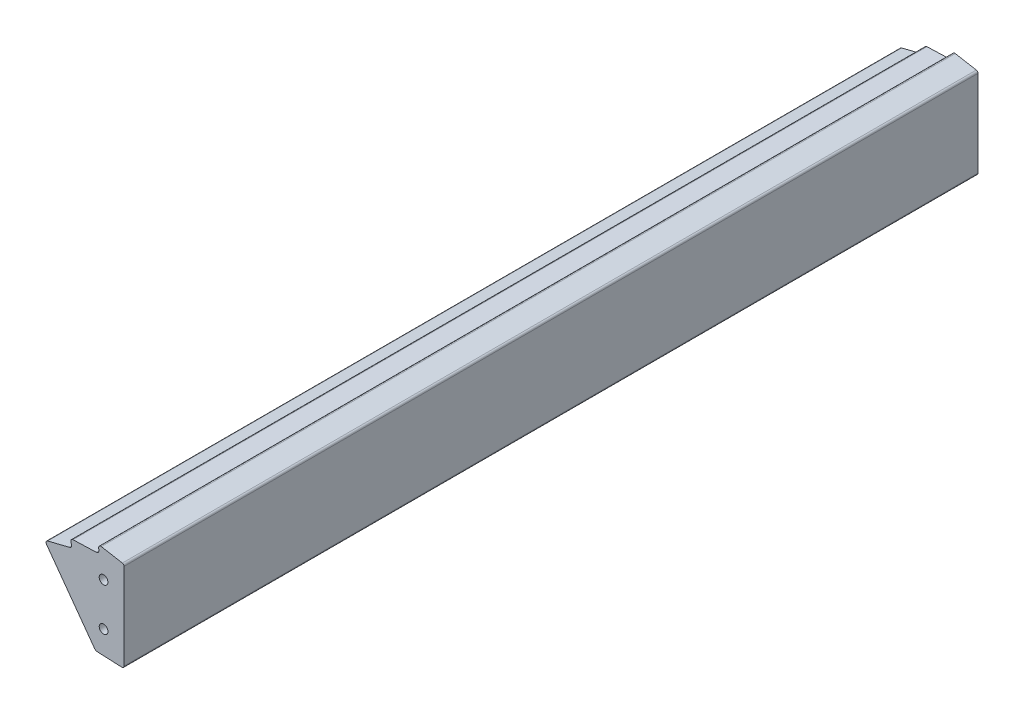
from build123d import *

# Parameters (mm, degrees)
EXTRUDE_THIN1_DEPTH                   = 137.50025
EXTRUDE_THIN1_DEPTH_BACK              = 213.5
BOSS_EXTRUDE1_DEPTH                   = 212.50025
BOSS_EXTRUDE1_DEPTH_BACK              = 288.5
SKETCH3_OUTSIDE_W                     = 604.22
SKETCH3_OUTSIDE_H                     = 158.409
SKETCH3_OUTSIDE_W_2                   = 500
SKETCH3_OUTSIDE_H_2                   = 100
CUT_EXTRUDE1_DEPTH                    = 47.9721863
F_1_4_20_TAPPED_HOLE1_D               = 5.1054
F_1_4_20_TAPPED_HOLE1_DEPTH           = 16.51
F_1_4_20_TAPPED_HOLE1_TIP             = 1.533816902
F_1_4_20_TAPPED_HOLE1_ON_FACE_2_D     = 5.1054
F_1_4_20_TAPPED_HOLE1_ON_FACE_2_DEPTH = 16.51
F_1_4_20_TAPPED_HOLE1_ON_FACE_2_TIP   = 1.533816902


with BuildPart() as part:
    # Sketch1 → Extrude-Thin1 (new body, two sides)
    with BuildSketch(Plane.XY) as extrude_thin1_sk:
        with BuildLine():
            Line((-1, 27.377741566), (-1, 77.801426032))
            ThreePointArc((-1, 77.801426032), (-1.350622843, 78.765237295), (-2.238576202, 79.278469565))
            Line((-2.238576202, 79.278469565), (-14.558703221, 81.459024387))
            ThreePointArc((-14.558703221, 81.459024387), (-15.894736771, 81.028505523), (-16.289731152, 79.681541685))
            Line((-16.289731152, 79.681541685), (-16.133756174, 78.918587001))
            ThreePointArc((-16.133756174, 78.918587001), (-16.425245763, 77.689683441), (-17.551976749, 77.11902818))
            Line((-17.551976749, 77.11902818), (-31.176844118, 76.65202466))
            ThreePointArc((-31.176844118, 76.65202466), (-32.394172225, 75.953136671), (-32.500485501, 74.553483275))
            Line((-32.500485501, 74.553483275), (-32.189291753, 73.839630003))
            ThreePointArc((-32.189291753, 73.839630003), (-32.218908178, 72.576976841), (-33.202371488, 71.784531222))
            Line((-33.202371488, 71.784531222), (-46.048094302, 68.590520723))
            ThreePointArc((-46.048094302, 68.590520723), (-47.095522714, 67.648327859), (-46.899674588, 66.253165796))
            Line((-46.899674588, 66.253165796), (-18.735090298, 27.487941181))
            ThreePointArc((-18.735090298, 27.487941181), (-17.958226336, 26.809018221), (-16.963801619, 26.534111898))
            Line((-16.963801619, 26.534111898), (-2.568160686, 25.879290992))
            ThreePointArc((-2.568160686, 25.879290992), (-1.463718433, 26.293250665), (-1, 27.377741566))
        make_face()
        with BuildLine():
            Line((-1.27, 27.377741566), (-1.27, 77.801426032))
            ThreePointArc((-1.27, 77.801426032), (-1.557510731, 78.591751268), (-2.285632486, 79.012601729))
            Line((-2.285632486, 79.012601729), (-14.605759505, 81.193156552))
            ThreePointArc((-14.605759505, 81.193156552), (-15.701307016, 80.840131082), (-16.025202408, 79.735620736))
            Line((-16.025202408, 79.735620736), (-15.86922743, 78.972666052))
            ThreePointArc((-15.86922743, 78.972666052), (-16.213185146, 77.522559851), (-17.542727708, 76.849186643))
            Line((-17.542727708, 76.849186643), (-31.167595078, 76.382183123))
            ThreePointArc((-31.167595078, 76.382183123), (-32.165804125, 75.809094972), (-32.252981012, 74.661379187))
            Line((-32.252981012, 74.661379187), (-31.941787264, 73.947525915))
            ThreePointArc((-31.941787264, 73.947525915), (-31.976734646, 72.457595184), (-33.137221351, 71.522509354))
            Line((-33.137221351, 71.522509354), (-45.982944165, 68.328498854))
            ThreePointArc((-45.982944165, 68.328498854), (-46.841835463, 67.555900706), (-46.68124, 66.411867814))
            Line((-46.68124, 66.411867814), (-18.516655709, 27.646643199))
            ThreePointArc((-18.516655709, 27.646643199), (-17.830213301, 27.046742143), (-16.951532696, 26.803833001))
            Line((-16.951532696, 26.803833001), (-2.555891763, 26.149012095))
            ThreePointArc((-2.555891763, 26.149012095), (-1.650249115, 26.488459027), (-1.27, 27.377741566))
        make_face(mode=Mode.SUBTRACT)
    extrude(amount=EXTRUDE_THIN1_DEPTH)
    extrude(extrude_thin1_sk.sketch, amount=-EXTRUDE_THIN1_DEPTH_BACK)


with BuildPart() as body_2:
    # Sketch2 → Boss-Extrude1 (new body, two sides)
    with BuildSketch(Plane.XY) as boss_extrude1_sk:
        with BuildLine():
            Line((-46.68124, 66.411867814), (-18.516655709, 27.646643199))
            ThreePointArc((-18.516655709, 27.646643199), (-17.830213301, 27.046742143), (-16.951532696, 26.803833001))
            Line((-16.951532696, 26.803833001), (-2.555891763, 26.149012095))
            ThreePointArc((-2.555891763, 26.149012095), (-1.650249115, 26.488459027), (-1.27, 27.377741566))
            Line((-1.27, 27.377741566), (-1.27, 77.801426032))
            Line((-1.27, 77.801426032), (-1.27, 77.950492711))
            ThreePointArc((-1.27, 77.950492711), (-1.551343626, 78.723865471), (-2.263847169, 79.13568869))
            Line((-2.263847169, 79.13568869), (-14.583974188, 81.316243513))
            ThreePointArc((-14.583974188, 81.316243513), (-15.790857829, 80.927341471), (-16.147669419, 79.710584138))
            Line((-16.147669419, 79.710584138), (-15.991694441, 78.947629454))
            ThreePointArc((-15.991694441, 78.947629454), (-16.311361358, 77.599931884), (-17.547009672, 76.97411328))
            Line((-17.547009672, 76.97411328), (-31.171877041, 76.50710976))
            ThreePointArc((-31.171877041, 76.50710976), (-32.271530097, 75.875780943), (-32.367566424, 74.611427376))
            Line((-32.367566424, 74.611427376), (-32.056372675, 73.897574104))
            ThreePointArc((-32.056372675, 73.897574104), (-32.088852022, 72.51286447), (-33.167383452, 71.643815774))
            Line((-33.167383452, 71.643815774), (-46.013106265, 68.449805275))
            ThreePointArc((-46.013106265, 68.449805275), (-46.895812161, 67.655785191), (-46.730763846, 66.48003154))
            Line((-46.730763846, 66.48003154), (-46.68124, 66.411867814))
        make_face()
    extrude(amount=BOSS_EXTRUDE1_DEPTH)
    extrude(boss_extrude1_sk.sketch, amount=-BOSS_EXTRUDE1_DEPTH_BACK)

    # Sketch3 outside → Cut-Extrude1 (cut, through all)
    with BuildSketch(Plane(origin=(0, 0, 0), x_dir=(0, 0, -1), z_dir=(1, 0, 0))):
        with Locations((38, 53.7425)):
            Rectangle(SKETCH3_OUTSIDE_W, SKETCH3_OUTSIDE_H)
        with Locations((37.999875, 52.664117138)):
            Rectangle(SKETCH3_OUTSIDE_W_2, SKETCH3_OUTSIDE_H_2, mode=Mode.SUBTRACT)
    extrude(amount=-CUT_EXTRUDE1_DEPTH, mode=Mode.SUBTRACT)

    # 1/4-20 Tapped Hole1
    with Locations(Plane(origin=(-13.27, 65.164117138, 212.000125), x_dir=(1, 0, 0), z_dir=(0, 0, 1))):
        with Locations((0, 0), (0, -25)):
            Hole(F_1_4_20_TAPPED_HOLE1_D / 2, depth=F_1_4_20_TAPPED_HOLE1_DEPTH)
            with Locations((0, 0, -(F_1_4_20_TAPPED_HOLE1_DEPTH + F_1_4_20_TAPPED_HOLE1_TIP / 2))):  # 118° drill point
                Cone(0, F_1_4_20_TAPPED_HOLE1_D / 2, F_1_4_20_TAPPED_HOLE1_TIP, mode=Mode.SUBTRACT)

    # 1/4-20 Tapped Hole1 on face 2
    with Locations(Plane(origin=(-13.27, 65.164117138, -287.999875), x_dir=(-1, 0, 0), z_dir=(0, 0, -1))):
        with Locations((0, 0), (0, -25)):
            Hole(F_1_4_20_TAPPED_HOLE1_ON_FACE_2_D / 2, depth=F_1_4_20_TAPPED_HOLE1_ON_FACE_2_DEPTH)
            with Locations((0, 0, -(F_1_4_20_TAPPED_HOLE1_ON_FACE_2_DEPTH + F_1_4_20_TAPPED_HOLE1_ON_FACE_2_TIP / 2))):  # 118° drill point
                Cone(0, F_1_4_20_TAPPED_HOLE1_ON_FACE_2_D / 2, F_1_4_20_TAPPED_HOLE1_ON_FACE_2_TIP, mode=Mode.SUBTRACT)


solid = body_2.part
